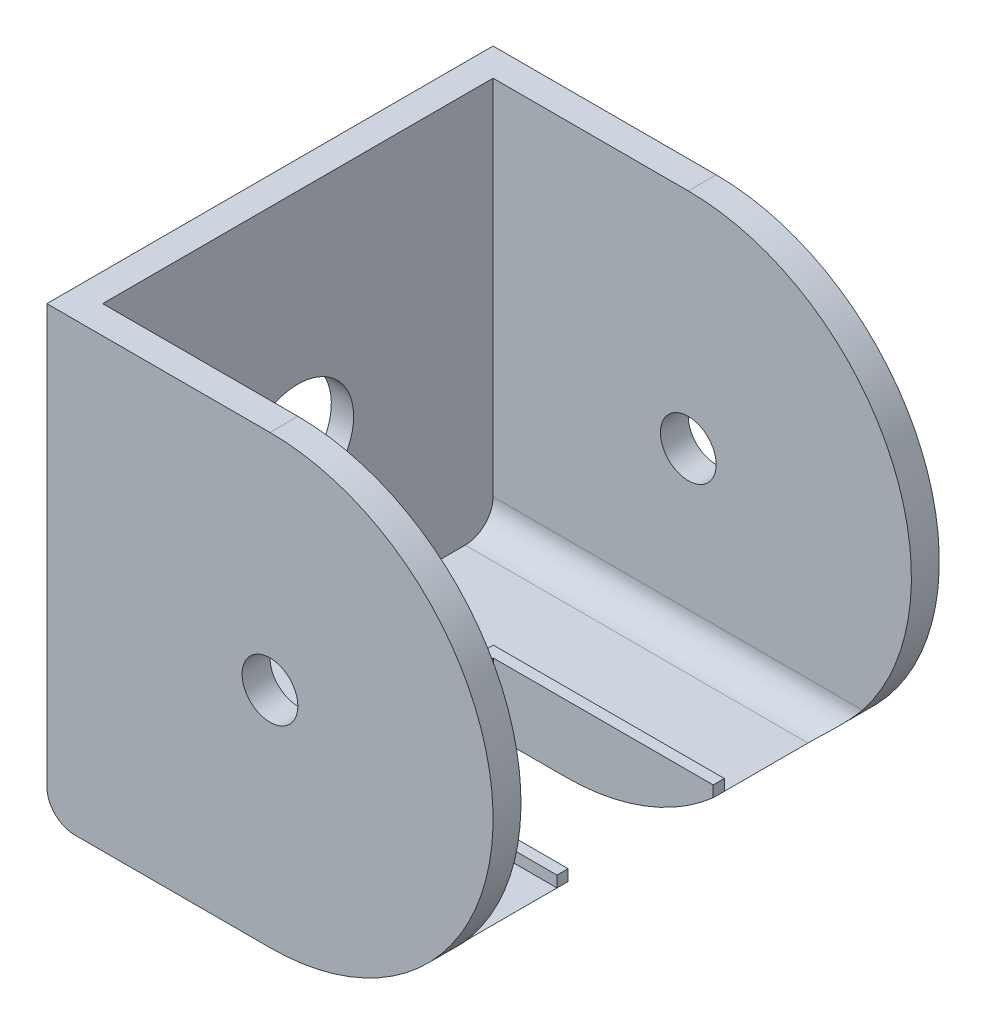
from build123d import *

# Parameters (mm, degrees)
SKETCH1_R           = 4.9999999999999964
BOSS_EXTRUDE1_DEPTH = 5
BOSS_EXTRUDE2_DEPTH = 70
BOSS_EXTRUDE3_DEPTH = 70
CUT_EXTRUDE1_DEPTH  = 5
SKETCH6_R           = 20.000000000000004
CUT_EXTRUDE2_DEPTH  = 1
CUT_EXTRUDE3_DEPTH  = 19.000000000000004
BOSS_EXTRUDE4_DEPTH = 1.9999999999999896
FILLET1_R           = 5


with BuildPart() as part:
    # Sketch1 → Boss-Extrude1 (new body)
    with BuildSketch(Plane.XY):
        with BuildLine():
            Line((-7.704615384615421, -40.00000000000001), (32.295384615384584, -40.00000000000001))
            ThreePointArc((32.295384615384584, -40.00000000000001), (72.29538461538459, 0), (32.29538461538458, 39.99999999999999))
            Line((32.29538461538458, 39.99999999999999), (-7.7046153846154315, 39.99999999999999))
            Line((-7.7046153846154315, 39.99999999999999), (-7.704615384615421, -40.00000000000001))
        make_face()
        with Locations((32.295384615384584, 0)):
            Circle(SKETCH1_R, mode=Mode.SUBTRACT)
    boss_extrude1 = extrude(amount=BOSS_EXTRUDE1_DEPTH)

    # Sketch2 → Boss-Extrude2 (add)
    with BuildSketch(Plane.XY.offset(5)):
        Polygon((-7.7046153846154315, 39.99999999999999), (-2.70461538461543, 39.99999999999999), (-2.7046153846154235, -40.00000000000001), (-7.704615384615421, -40.00000000000001), align=None)
    extrude(amount=BOSS_EXTRUDE2_DEPTH)

    # Mirror1: Boss-Extrude1 across plane
    add(boss_extrude1.mirror(Plane.XY.offset(40)))

    # Sketch4 → Boss-Extrude3 (add)
    with BuildSketch(Plane.XY.offset(5)):
        with BuildLine():
            Line((-2.7046153846154266, -40.00000000000001), (-2.7046153846154266, -30.000000000000007))
            Line((-2.7046153846154266, -30.000000000000007), (43.497251593214216, -30.000000000000007))
            Line((43.497251593214216, -30.000000000000007), (58.7528977260305, -30.000000000000007))
            ThreePointArc((58.7528977260305, -30.000000000000007), (46.43752023911554, -37.41657386773942), (32.295384615384584, -40.00000000000001))
            Line((32.295384615384584, -40.00000000000001), (-2.7046153846154266, -40.00000000000001))
        make_face()
    extrude(amount=BOSS_EXTRUDE3_DEPTH)

    # Sketch5 → Cut-Extrude1 (cut)
    with BuildSketch(Plane.ZY.offset(7.704615384615426)):
        with BuildLine():
            ThreePointArc((50.00000000000001, -1.388e-14), (43.82683432365097, 9.238795325112829), (32.92893218813463, 7.071067811865561))
            Line((32.92893218813452, 7.0710678118654755), (47.071067811865476, -7.071067811865483))
            ThreePointArc((47.0710678118656, -7.0710678118653725), (49.2387953251129, -3.826834323650836), (50.00000000000001, -1.633e-14))
        make_face()
        with BuildLine():
            Line((47.071067811865476, -7.071067811865483), (32.92893218813452, 7.0710678118654755))
            ThreePointArc((32.92893218813463, 7.071067811865561), (32.92893218813454, -7.071067811865502), (47.0710678118656, -7.0710678118653725))
        make_face()
    extrude(amount=-CUT_EXTRUDE1_DEPTH, mode=Mode.SUBTRACT)

    # Sketch6 → Cut-Extrude2 (cut)
    with BuildSketch(Plane.ZY.offset(7.704615384615426)):
        with Locations(Location((40.00000000000001, -1.388e-14, 0), (0, 0, 270))):
            Circle(SKETCH6_R)
    extrude(amount=-CUT_EXTRUDE2_DEPTH, mode=Mode.SUBTRACT)

    # Sketch7 → Cut-Extrude3 (cut)
    with BuildSketch(Plane(origin=(0, -30.000000000000007, 0), x_dir=(1, 0, 0), z_dir=(0, 1, 0))):
        Polygon((58.7528977260305, -53.00000000000001), (58.7528977260305, -40.00000000000001), (58.7528977260305, -27.000000000000004), (19.339689979409883, -27.000000000000007), (19.339689979409883, -53.00000000000001), align=None)
    extrude(amount=-CUT_EXTRUDE3_DEPTH, mode=Mode.SUBTRACT)

    # Sketch8 → Boss-Extrude4 (add)
    with BuildSketch(Plane(origin=(0, -30.000000000000007, 0), x_dir=(1, 0, 0), z_dir=(0, 1, 0))):
        Polygon((58.7528977260305, -53.00000000000001), (19.33968997940988, -53.00000000000001), (19.33968997940988, -27.000000000000007), (58.7528977260305, -27.000000000000004), (58.7528977260305, -25.000000000000007), (56.7528977260305, -25.000000000000007), (17.33968997940988, -25.000000000000007), (17.33968997940988, -55.00000000000001), (58.7528977260305, -55.00000000000001), align=None)
    extrude(amount=BOSS_EXTRUDE4_DEPTH)

    # Fillet1
    fillet1_edges = [part.edges().sort_by_distance(p)[0] for p in [
        (-7.704615384615421, -40.00000000000001, 40),
        (28.024141170707534, -30.000000000000007, 5),
        (28.024141170707537, -30.000000000000007, 75),
    ]]
    fillet(fillet1_edges, radius=FILLET1_R)


solid = part.part
